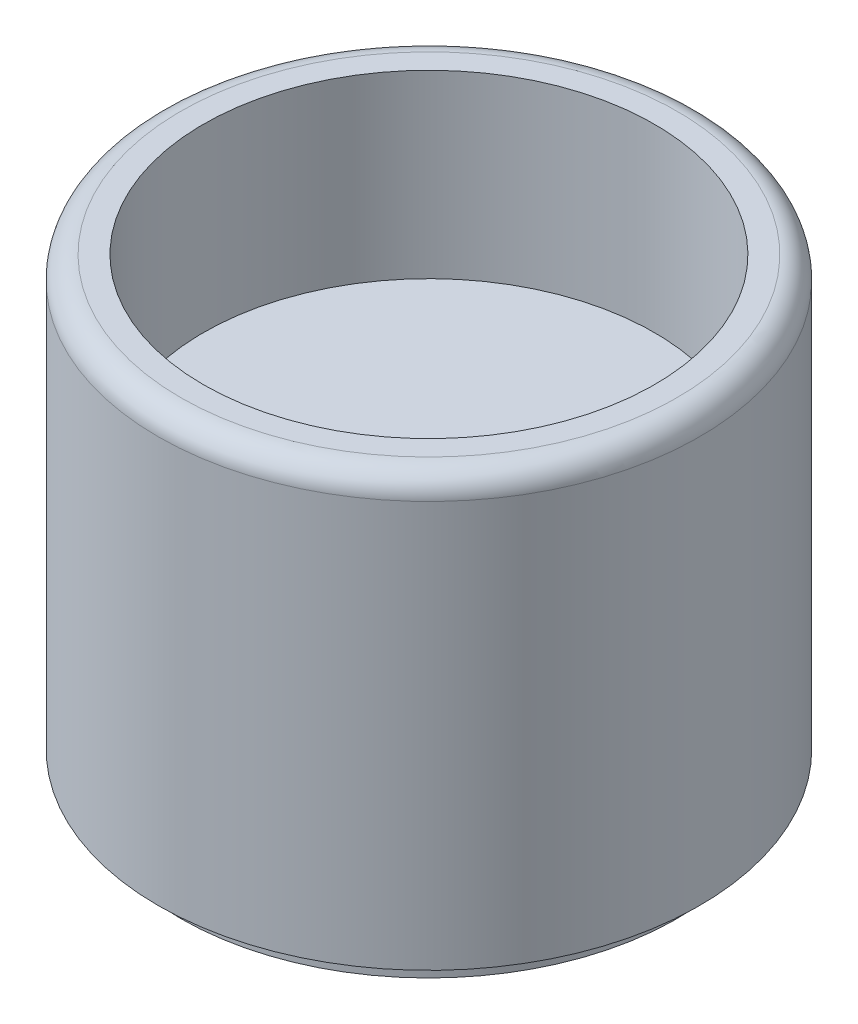
from build123d import *

# Parameters (mm, degrees)
SKETCH1_R           = 6
BOSS_EXTRUDE1_DEPTH = 10
FILLET1_R           = 0.5
SKETCH2_OUTSIDE_W   = 17.94
SKETCH2_OUTSIDE_H   = 17.94
SKETCH2_OUTSIDE_R   = 5.5
CUT_EXTRUDE11_DEPTH = 0.5
SKETCH3_R           = 5
CUT_EXTRUDE12_DEPTH = 4


with BuildPart() as part:
    # Sketch1 → Boss-Extrude1 (new body)
    with BuildSketch(Plane(origin=(0, 0, 0), x_dir=(1, 0, 0), z_dir=(0, 1, 0))):
        Circle(SKETCH1_R)
    extrude(amount=BOSS_EXTRUDE1_DEPTH)

    # Fillet1
    fillet1_edges = [part.edges().sort_by_distance(p)[0] for p in [
        (-6, 10, 0),
    ]]
    fillet(fillet1_edges, radius=FILLET1_R)

    # Sketch2 outside → Cut-Extrude11 (cut)
    with BuildSketch(Plane(origin=(0, 0, 0), x_dir=(1, 0, 0), z_dir=(0, 1, 0))):
        Rectangle(SKETCH2_OUTSIDE_W, SKETCH2_OUTSIDE_H)
        Circle(SKETCH2_OUTSIDE_R, mode=Mode.SUBTRACT)
    extrude(amount=CUT_EXTRUDE11_DEPTH, mode=Mode.SUBTRACT)

    # Sketch3 → Cut-Extrude12 (cut)
    with BuildSketch(Plane(origin=(0, 10, 0), x_dir=(1, 0, 0), z_dir=(0, 1, 0))):
        Circle(SKETCH3_R)
    extrude(amount=-CUT_EXTRUDE12_DEPTH, mode=Mode.SUBTRACT)


solid = part.part
